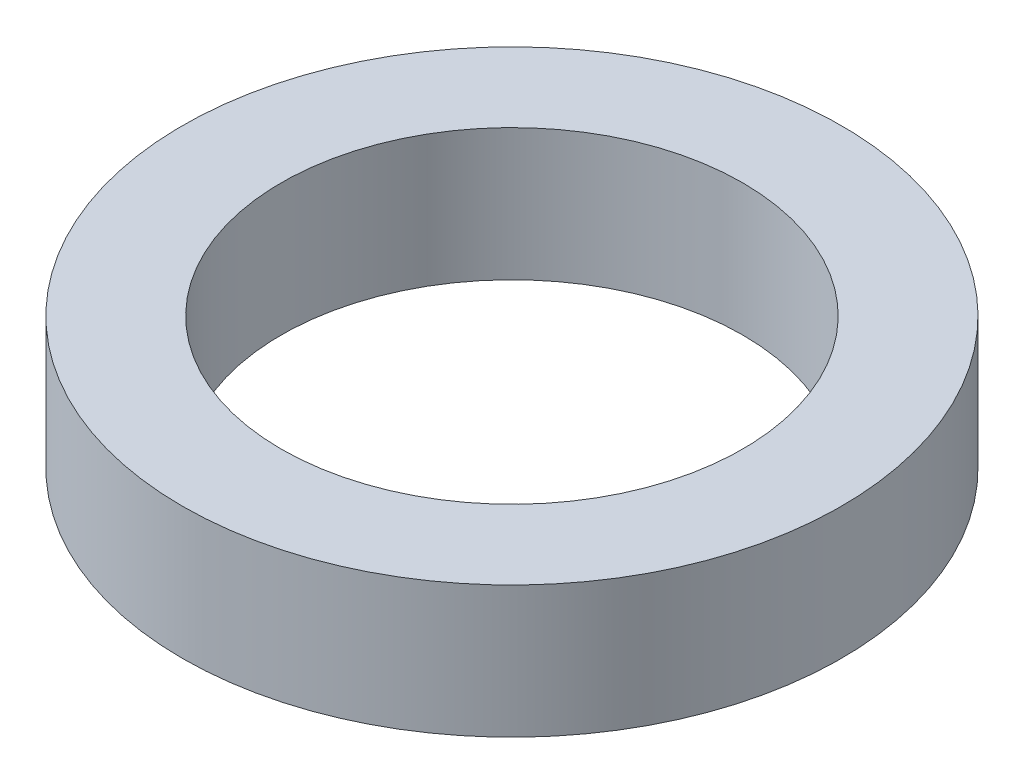
from build123d import *

# Parameters (mm, degrees)
SKETCH1_R           = 25
SKETCH1_R_2         = 17.5
BOSS_EXTRUDE1_DEPTH = 10


with BuildPart() as part:
    # Sketch1 → Boss-Extrude1 (new body)
    with BuildSketch(Plane(origin=(0, 0, 0), x_dir=(1, 0, 0), z_dir=(0, 1, 0))):
        Circle(SKETCH1_R)
        Circle(SKETCH1_R_2, mode=Mode.SUBTRACT)
    extrude(amount=BOSS_EXTRUDE1_DEPTH)


solid = part.part
